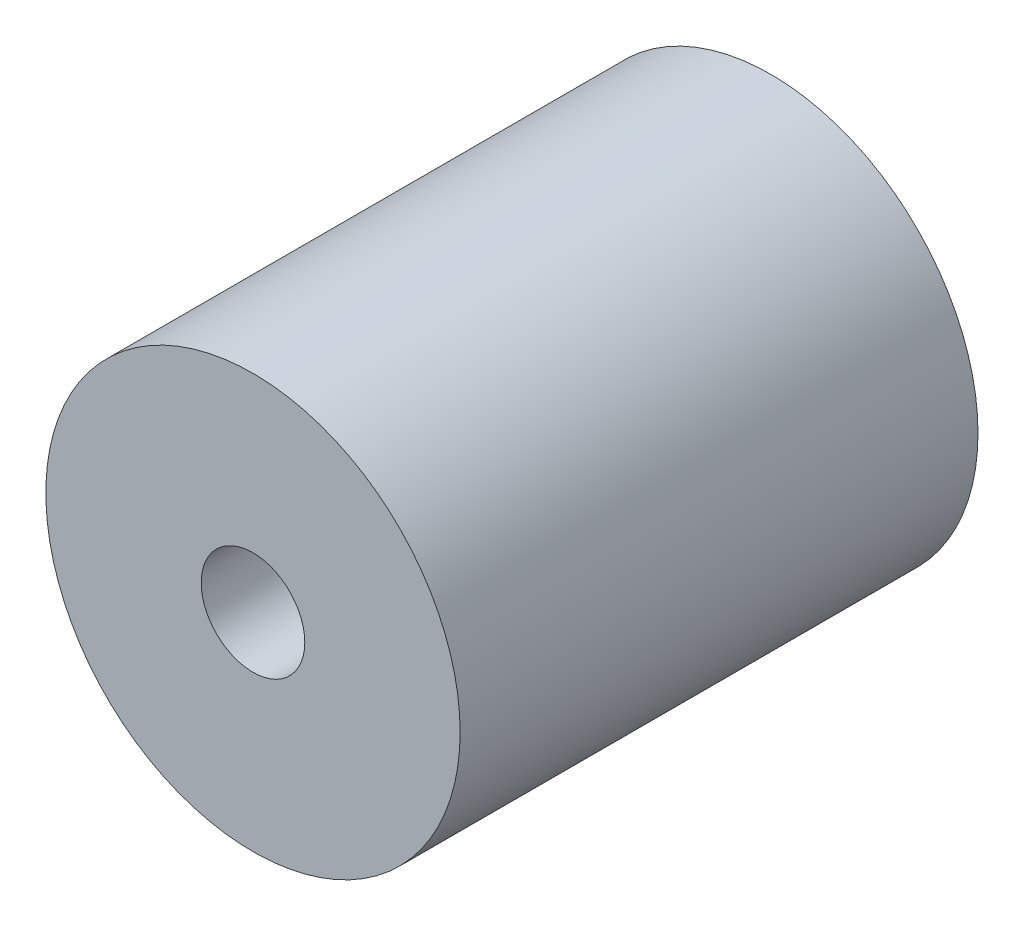
from build123d import *

# Parameters (mm, degrees)
SKETCH1_R           = 10
BOSS_EXTRUDE1_DEPTH = 25
SKETCH2_R           = 2.5
CUT_EXTRUDE1_DEPTH  = 10
SKETCH3_R           = 4
CUT_EXTRUDE2_DEPTH  = 10


with BuildPart() as part:
    # Sketch1 → Boss-Extrude1 (new body)
    with BuildSketch(Plane.XY):
        Circle(SKETCH1_R)
    extrude(amount=BOSS_EXTRUDE1_DEPTH)

    # Sketch2 → Cut-Extrude1 (cut)
    with BuildSketch(Plane.XY.offset(25)):
        Circle(SKETCH2_R)
    extrude(amount=-CUT_EXTRUDE1_DEPTH, mode=Mode.SUBTRACT)

    # Sketch3 → Cut-Extrude2 (cut)
    with BuildSketch(Plane(origin=(0, 0, 0), x_dir=(-1, 0, 0), z_dir=(0, 0, -1))):
        Circle(SKETCH3_R)
    extrude(amount=-CUT_EXTRUDE2_DEPTH, mode=Mode.SUBTRACT)


solid = part.part
